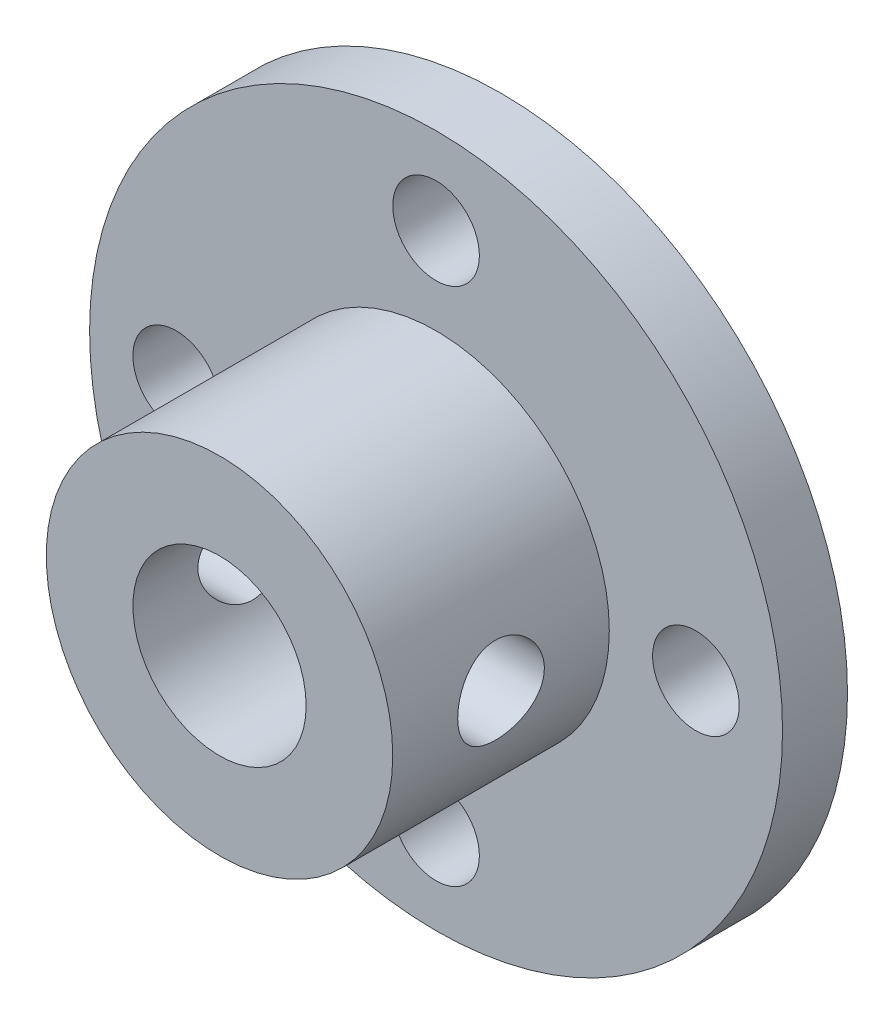
from build123d import *

# Parameters (mm, degrees)
SKETCH1_R               = 16
SKETCH1_R_2             = 2
SKETCH1_R_3             = 8
BOSS_EXTRUDE1_DEPTH     = 3
SKETCH1_3_R             = 8
SKETCH1_3_R_2           = 4
BOSS_EXTRUDE2_DEPTH     = 13
CUT_EXTRUDE1_DEPTH      = 27.095976701
CUT_EXTRUDE1_DEPTH_BACK = 27.095976701
SKETCH2_R               = 2


with BuildPart() as part:
    # Sketch1 → Boss-Extrude1 (new body)
    with BuildSketch(Plane(origin=(0, 0, 0), x_dir=(0, 1, 0), z_dir=(0, 0, 1))):
        Circle(SKETCH1_R)
        with Locations((0, -12)):
            Circle(SKETCH1_R_2, mode=Mode.SUBTRACT)
        with Locations((12, 0)):
            Circle(SKETCH1_R_2, mode=Mode.SUBTRACT)
        with Locations((-12, 0)):
            Circle(SKETCH1_R_2, mode=Mode.SUBTRACT)
        Circle(SKETCH1_R_3, mode=Mode.SUBTRACT)
        with Locations((0, 12)):
            Circle(SKETCH1_R_2, mode=Mode.SUBTRACT)
    extrude(amount=BOSS_EXTRUDE1_DEPTH)

    # Sketch1_3 → Boss-Extrude2 (add)
    with BuildSketch(Plane(origin=(0, 0, 0), x_dir=(0, 1, 0), z_dir=(0, 0, 1))):
        Circle(SKETCH1_3_R)
        Circle(SKETCH1_3_R_2, mode=Mode.SUBTRACT)
    extrude(amount=BOSS_EXTRUDE2_DEPTH)

    # Sketch2 → Cut-Extrude1 (cut, two sides: drawn at the far end of the back side and taken through both)
    with BuildSketch(Plane.YZ.offset(-CUT_EXTRUDE1_DEPTH_BACK)):
        with Locations((0, 8)):
            Circle(SKETCH2_R)
    extrude(amount=CUT_EXTRUDE1_DEPTH + CUT_EXTRUDE1_DEPTH_BACK, mode=Mode.SUBTRACT)


solid = part.part
